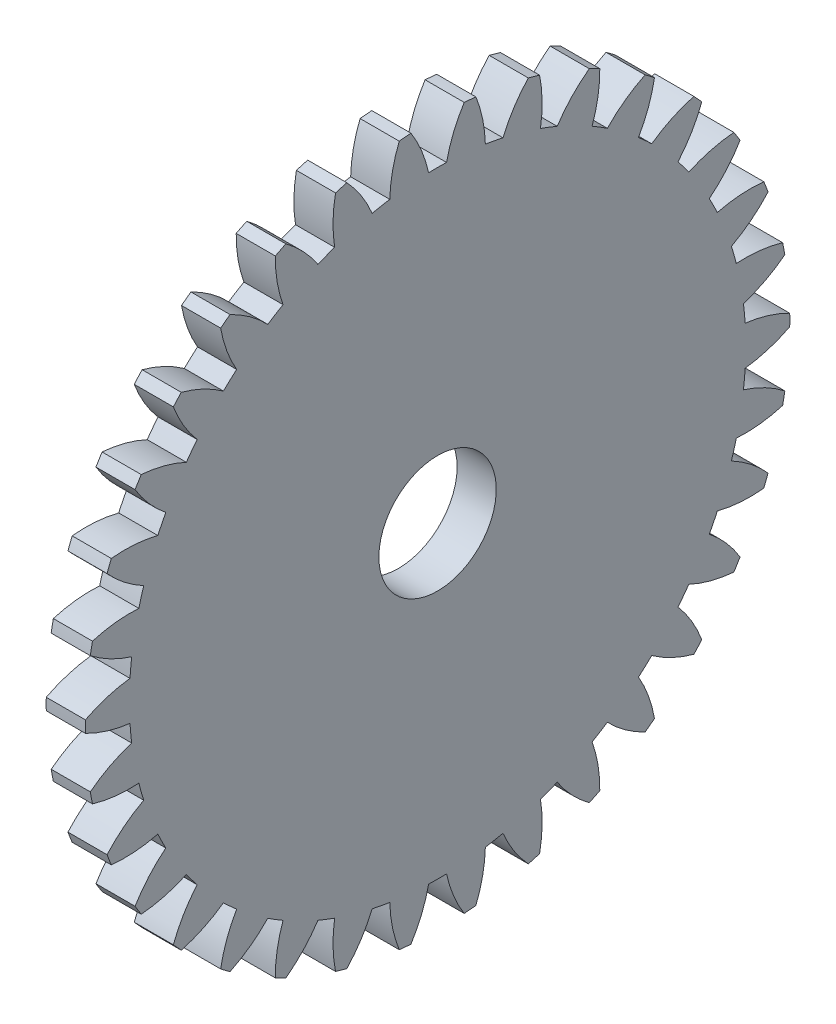
from build123d import *

# Parameters (mm, degrees)
BASPROSKE_W     = 2
BASPROSKE_H     = 18
TOOTHCUT_DEPTH  = 26.53429067
TEETHCUTS_COUNT = 34
TEETHCUTS_ANGLE = 349.411764706
BORSKE_R        = 3
BORE_DEPTH      = 50.0000508


with BuildPart() as part:
    # BasProSke → Base-Revolve (revolve)
    with BuildSketch(Plane(origin=(0, 0, 0), x_dir=(1, 0, 0), z_dir=(0, 1, 0)), mode=Mode.PRIVATE) as base_revolve_sk:
        with Locations((1, 9)):
            Rectangle(BASPROSKE_W, BASPROSKE_H)
    revolve(base_revolve_sk.sketch.rotate(Axis((-10, 0, 0), (1, 0, 0)), 180), axis=Axis((-10, 0, 0), (1, 0, 0)))

    # TooCutSke → ToothCut (cut, through all)
    with BuildSketch(Plane(origin=(0, 0, 0), x_dir=(0, 0, -1), z_dir=(1, 0, 0))):
        with BuildLine():
            ThreePointArc((0.458149848, 15.742334634), (0, 15.749), (-0.458149848, 15.742334634))
            ThreePointArc((-0.458149848, 15.742334634), (-0.818018246, 16.898604037), (-1.377276242, 17.972705843))
            ThreePointArc((-1.377276242, 17.972705843), (0, 18.0254), (1.377276242, 17.972705843))
            ThreePointArc((1.377276242, 17.972705843), (0.818018246, 16.898604037), (0.458149848, 15.742334634))
        make_face()
    toothcut = extrude(amount=TOOTHCUT_DEPTH, mode=Mode.SUBTRACT)

    # TeethCuts: ToothCut ×34 about axis
    teethcuts_axis = Axis((-10, 0, 0), (1, 0, 0))
    for i in range(1, TEETHCUTS_COUNT):
        add(toothcut.rotate(teethcuts_axis, i * TEETHCUTS_ANGLE / (TEETHCUTS_COUNT - 1)), mode=Mode.SUBTRACT)

    # BorSke → Bore (cut, symmetric)
    with BuildSketch(Plane(origin=(0, 0, 0), x_dir=(0, 0, -1), z_dir=(1, 0, 0))):
        with Locations(Location((0, 0, 0), (0, 0, 180))):
            Circle(BORSKE_R)
    extrude(amount=BORE_DEPTH, both=True, mode=Mode.SUBTRACT)


solid = part.part
